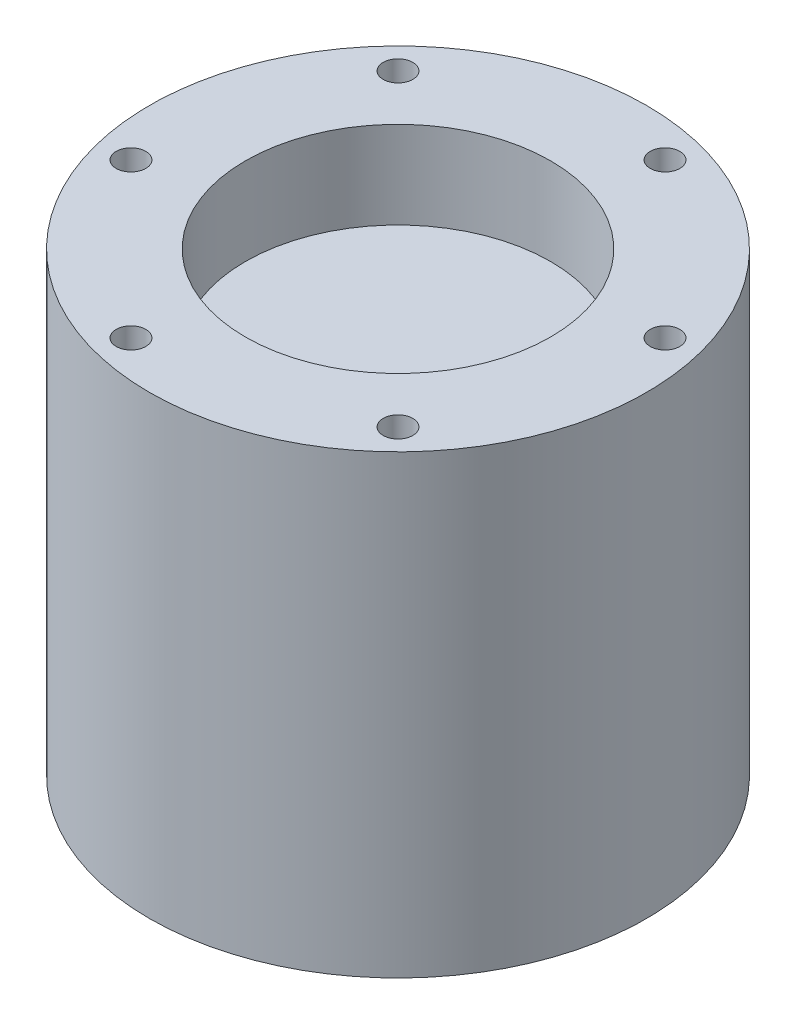
from build123d import *

# Parameters (mm, degrees)
SKETCH_1_R          = 28.5
EXTRUDE_1_DEPTH     = 52.25
SKETCH_3_R          = 17.5
CUT_EXTRUDE_2_DEPTH = 10
SKETCH_4_R          = 1.7
CUT_EXTRUDE_3_DEPTH = 10
SKETCH_5_R          = 1.5
CUT_EXTRUDE_4_DEPTH = 10


with BuildPart() as part:
    # 草图1 → 凸台-拉伸1 (new body)
    with BuildSketch(Plane(origin=(0, 0, 0), x_dir=(1, 0, 0), z_dir=(0, 1, 0))):
        Circle(SKETCH_1_R)
    extrude(amount=EXTRUDE_1_DEPTH)

    # 草图3 → 切除-拉伸2 (cut)
    with BuildSketch(Plane(origin=(0, 52.25, 0), x_dir=(1, 0, 0), z_dir=(0, 1, 0))):
        Circle(SKETCH_3_R)
    extrude(amount=-CUT_EXTRUDE_2_DEPTH, mode=Mode.SUBTRACT)

    # 草图4 → 切除-拉伸3 (cut)
    with BuildSketch(Plane(origin=(0, 52.25, 0), x_dir=(1, 0, 0), z_dir=(0, 1, 0))):
        with Locations((17.67766953, -17.67766953)):
            Circle(SKETCH_4_R)
        with Locations((-6.470476128, -24.148145657)):
            Circle(SKETCH_4_R)
        with Locations((-24.148145657, -6.470476128)):
            Circle(SKETCH_4_R)
        with Locations((-17.67766953, 17.67766953)):
            Circle(SKETCH_4_R)
        with Locations((6.470476128, 24.148145657)):
            Circle(SKETCH_4_R)
        with Locations((24.148145657, 6.470476128)):
            Circle(SKETCH_4_R)
    extrude(amount=-CUT_EXTRUDE_3_DEPTH, mode=Mode.SUBTRACT)

    # 草图5 → 切除-拉伸4 (cut)
    with BuildSketch(Plane.XZ):
        with Locations((0, -19)):
            Circle(SKETCH_5_R)
        with Locations((-19, 0)):
            Circle(SKETCH_5_R)
        with Locations((0, 19)):
            Circle(SKETCH_5_R)
        with Locations((19, 0)):
            Circle(SKETCH_5_R)
    extrude(amount=-CUT_EXTRUDE_4_DEPTH, mode=Mode.SUBTRACT)


solid = part.part
